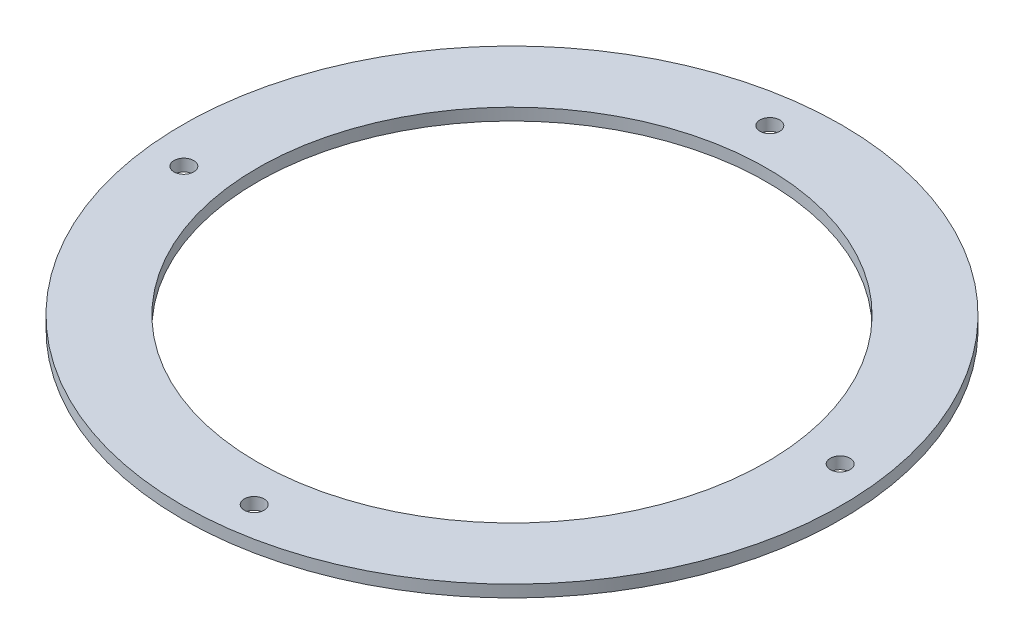
from build123d import *

# Parameters (mm, degrees)
SKETCH_1_R          = 55
EXTRUDE_1_DEPTH     = 2
SKETCH_2_R          = 1.65
CUT_EXTRUDE_1_DEPTH = 14
SKETCH_3_R          = 42.5
CUT_EXTRUDE_2_DEPTH = 14


with BuildPart() as part:
    # 草图1 → 凸台-拉伸1 (new body)
    with BuildSketch(Plane(origin=(0, 0, 0), x_dir=(1, 0, 0), z_dir=(0, 1, 0))):
        Circle(SKETCH_1_R)
    extrude(amount=EXTRUDE_1_DEPTH)

    # 草图2 → 切除-拉伸1 (cut)
    with BuildSketch(Plane(origin=(0, 2, 0), x_dir=(1, 0, 0), z_dir=(0, 1, 0))):
        with Locations((-48.898985831, -5.869555746)):
            Circle(SKETCH_2_R)
        with Locations((-5.869555746, 48.898985831)):
            Circle(SKETCH_2_R)
        with Locations((48.898985831, 5.869555746)):
            Circle(SKETCH_2_R)
        with Locations((5.869555746, -48.898985831)):
            Circle(SKETCH_2_R)
    extrude(amount=-CUT_EXTRUDE_1_DEPTH, mode=Mode.SUBTRACT)

    # 草图3 → 切除-拉伸2 (cut)
    with BuildSketch(Plane(origin=(0, 2, 0), x_dir=(1, 0, 0), z_dir=(0, 1, 0))):
        Circle(SKETCH_3_R)
    extrude(amount=-CUT_EXTRUDE_2_DEPTH, mode=Mode.SUBTRACT)


solid = part.part
